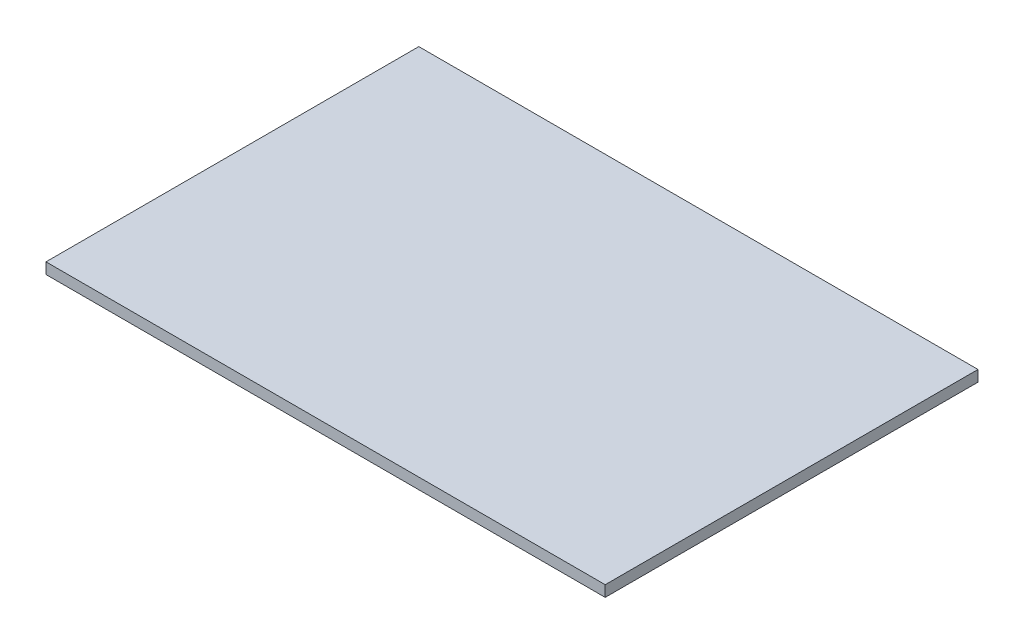
from build123d import *

# Parameters (mm, degrees)
SKETCH4_W           = 304.8
SKETCH4_H           = 203.2
BOSS_EXTRUDE2_DEPTH = 6


with BuildPart() as part:
    # Sketch4 → Boss-Extrude2 (new body)
    with BuildSketch(Plane(origin=(0, 0, 0), x_dir=(1, 0, 0), z_dir=(0, 1, 0))):
        Rectangle(SKETCH4_W, SKETCH4_H)
    extrude(amount=BOSS_EXTRUDE2_DEPTH)


solid = part.part
